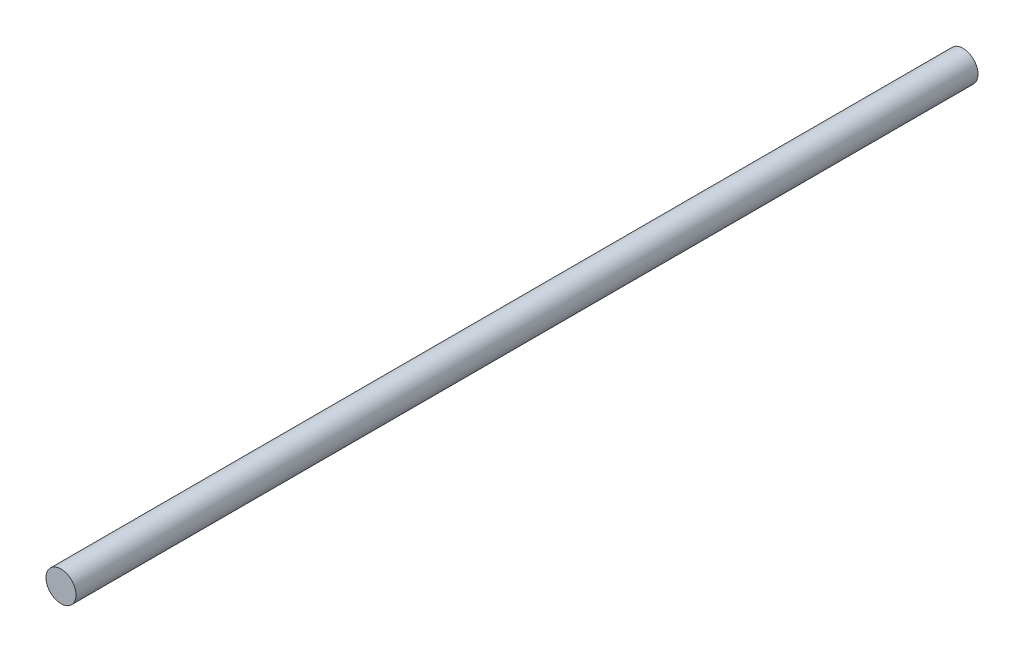
from build123d import *

# Parameters (mm, degrees)
SKETCH_1_R      = 0.75
EXTRUDE_1_DEPTH = 45


with BuildPart() as part:
    # 草图1 → 凸台-拉伸1 (new body)
    with BuildSketch(Plane.XY):
        Circle(SKETCH_1_R)
    extrude(amount=EXTRUDE_1_DEPTH)


solid = part.part
